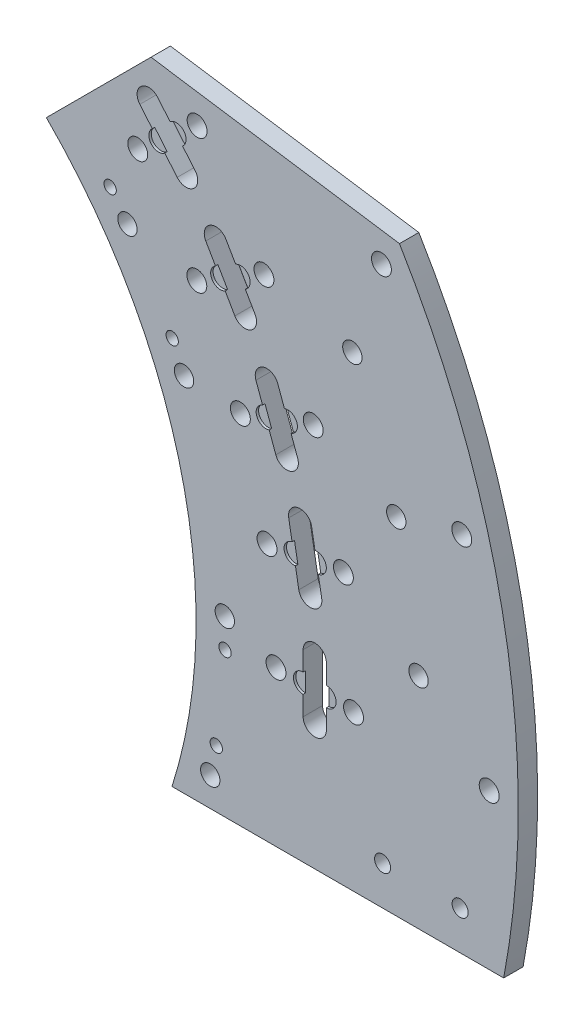
from build123d import *

# Parameters (mm, degrees)
SKETCH1_R           = 3.175
SKETCH1_R_2         = 3.2639
SKETCH1_R_3         = 2.6289
SKETCH1_R_4         = 2.0193
BOSS_EXTRUDE1_DEPTH = 6.35
SKETCH2_R           = 3.175
CUT_EXTRUDE1_DEPTH  = 0.79375


with BuildPart() as part:
    # Sketch1 → Boss-Extrude1 (new body)
    with BuildSketch(Plane.XY):
        with BuildLine():
            Line((159.591131024, -50.8), (268.282803213, -50.8))
            ThreePointArc((268.282803213, -50.8), (268.798556268, 47.996235774), (234.123018172, 140.508771477))
            Line((234.123018172, 140.508771477), (152.715190262, 152.715190262))
            Line((152.715190262, 152.715190262), (118.427127597, 118.427127597))
            ThreePointArc((118.427127597, 118.427127597), (154.732498954, 64.092299607), (167.48125, 0))
            ThreePointArc((167.48125, 0), (165.496965553, -25.70454229), (159.591131024, -50.8))
        make_face()
        with Locations((176.898422575, 6.177429038)):
            Circle(SKETCH1_R, mode=Mode.SUBTRACT)
        with Locations((144.995031539, 101.526614087)):
            Circle(SKETCH1_R, mode=Mode.SUBTRACT)
        with Locations((163.532451502, 67.7373593)):
            Circle(SKETCH1_R, mode=Mode.SUBTRACT)
        with Locations((172.12665951, -41.275)):
            Circle(SKETCH1_R, mode=Mode.SUBTRACT)
        with Locations((193.675, 0)):
            Circle(SKETCH1_R_2, mode=Mode.SUBTRACT)
        with Locations((219.075, 0)):
            Circle(SKETCH1_R_2, mode=Mode.SUBTRACT)
        with Locations((215.746758491, 38.041974522)):
            Circle(SKETCH1_R_2, mode=Mode.SUBTRACT)
        with Locations((190.732641565, 33.63131081)):
            Circle(SKETCH1_R_2, mode=Mode.SUBTRACT)
        with Locations((205.863160899, 74.928062899)):
            Circle(SKETCH1_R_2, mode=Mode.SUBTRACT)
        with Locations((181.994968331, 66.240751259)):
            Circle(SKETCH1_R_2, mode=Mode.SUBTRACT)
        with Locations((189.724515334, 109.5375)):
            Circle(SKETCH1_R_2, mode=Mode.SUBTRACT)
        with Locations((167.727470078, 96.8375)):
            Circle(SKETCH1_R_2, mode=Mode.SUBTRACT)
        with Locations((167.821186376, 140.818695592)):
            Circle(SKETCH1_R_2, mode=Mode.SUBTRACT)
        with Locations((148.363657521, 124.491890306)):
            Circle(SKETCH1_R_2, mode=Mode.SUBTRACT)
        with Locations((263.525, 0)):
            Circle(SKETCH1_R_2, mode=Mode.SUBTRACT)
        with Locations((254.545603373, 68.205288861)):
            Circle(SKETCH1_R_2, mode=Mode.SUBTRACT)
        with Locations((228.219344532, 131.7625)):
            Circle(SKETCH1_R_2, mode=Mode.SUBTRACT)
        with Locations((240.38178065, 21.030680725)):
            Circle(SKETCH1_R, mode=Mode.SUBTRACT)
        with Locations((233.077901884, 62.453035583)):
            Circle(SKETCH1_R, mode=Mode.SUBTRACT)
        with Locations((218.692069012, 101.977786558)):
            Circle(SKETCH1_R, mode=Mode.SUBTRACT)
        with Locations((228.6, -38.1)):
            Circle(SKETCH1_R_3, mode=Mode.SUBTRACT)
        with Locations((254, -38.1)):
            Circle(SKETCH1_R_3, mode=Mode.SUBTRACT)
        with Locations((159.651941396, 76.436052669)):
            Circle(SKETCH1_R_4, mode=Mode.SUBTRACT)
        with Locations((139.323763183, 109.179217581)):
            Circle(SKETCH1_R_4, mode=Mode.SUBTRACT)
        with Locations((176.974598028, -3.347266353)):
            Circle(SKETCH1_R_4, mode=Mode.SUBTRACT)
        with Locations((174.097718528, -31.956172212)):
            Circle(SKETCH1_R_4, mode=Mode.SUBTRACT)
        with BuildLine():
            Line((202.565, 0), (202.565, 9.525))
            ThreePointArc((202.565, 9.525), (206.375, 13.335), (210.185, 9.525))
            Line((210.185, 9.525), (210.185, 0))
            Line((210.185, 0), (210.185, -9.525))
            ThreePointArc((210.185, -9.525), (206.375, -13.335), (202.565, -9.525))
            Line((202.565, -9.525), (202.565, 0))
        make_face(mode=Mode.SUBTRACT)
        with BuildLine():
            Line((199.487582489, 35.175043109), (201.141581381, 25.794749262))
            ThreePointArc((201.141581381, 25.794749262), (205.555298477, 22.70423128), (208.645816459, 27.117948375))
            Line((208.645816459, 27.117948375), (206.991817567, 36.498242223))
            Line((206.991817567, 36.498242223), (205.337818675, 45.87853607))
            ThreePointArc((205.337818675, 45.87853607), (200.924101579, 48.969054052), (197.833583597, 44.555336957))
            Line((197.833583597, 44.555336957), (199.487582489, 35.175043109))
        make_face(mode=Mode.SUBTRACT)
        with BuildLine():
            Line((190.348835729, 69.281310333), (193.606577595, 60.33073812))
            ThreePointArc((193.606577595, 60.33073812), (198.489903226, 58.053605981), (200.767035365, 62.936931612))
            Line((200.767035365, 62.936931612), (197.5092935, 71.887503825))
            Line((197.5092935, 71.887503825), (194.251551635, 80.838076038))
            ThreePointArc((194.251551635, 80.838076038), (189.368226003, 83.115208177), (187.091093864, 78.231882546))
            Line((187.091093864, 78.231882546), (190.348835729, 69.281310333))
        make_face(mode=Mode.SUBTRACT)
        with BuildLine():
            Line((175.426435918, 101.2825), (180.188935918, 93.033608029))
            ThreePointArc((180.188935918, 93.033608029), (185.393492706, 91.639051241), (186.788049494, 96.843608029))
            Line((186.788049494, 96.843608029), (182.025549494, 105.0925))
            Line((182.025549494, 105.0925), (177.263049494, 113.341391971))
            ThreePointArc((177.263049494, 113.341391971), (172.058492706, 114.735948759), (170.663935918, 109.531391971))
            Line((170.663935918, 109.531391971), (175.426435918, 101.2825))
        make_face(mode=Mode.SUBTRACT)
        with BuildLine():
            Line((155.17379262, 130.206272156), (161.296344603, 122.909698835))
            ThreePointArc((161.296344603, 122.909698835), (166.663994724, 122.4400903), (167.133603259, 127.807740421))
            Line((167.133603259, 127.807740421), (161.011051277, 135.104313742))
            Line((161.011051277, 135.104313742), (154.888499295, 142.400887063))
            ThreePointArc((154.888499295, 142.400887063), (149.520849174, 142.870495598), (149.051240638, 137.502845477))
            Line((149.051240638, 137.502845477), (155.17379262, 130.206272156))
        make_face(mode=Mode.SUBTRACT)
    extrude(amount=BOSS_EXTRUDE1_DEPTH)

    # Sketch2 → Cut-Extrude1 (cut)
    with BuildSketch(Plane.XY.offset(6.35)):
        with Locations((202.565, 0)):
            Circle(SKETCH2_R)
        with Locations((210.185, 0)):
            Circle(SKETCH2_R)
        with Locations((199.487582489, 35.175043109)):
            Circle(SKETCH2_R)
        with Locations((206.991817567, 36.498242223)):
            Circle(SKETCH2_R)
        with Locations((190.348835729, 69.281310333)):
            Circle(SKETCH2_R)
        with Locations((197.5092935, 71.887503825)):
            Circle(SKETCH2_R)
        with Locations((175.426435918, 101.2825)):
            Circle(SKETCH2_R)
        with Locations((182.025549494, 105.0925)):
            Circle(SKETCH2_R)
        with Locations((155.17379262, 130.206272156)):
            Circle(SKETCH2_R)
        with Locations((161.011051277, 135.104313742)):
            Circle(SKETCH2_R)
    extrude(amount=-CUT_EXTRUDE1_DEPTH, mode=Mode.SUBTRACT)


solid = part.part
